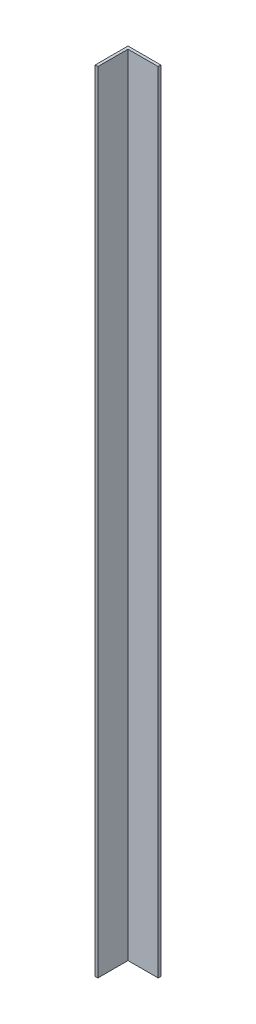
from build123d import *

# Parameters (mm, degrees)
EXTRUDE_THIN1_DEPTH = 457.2


with BuildPart() as part:
    # Sketch1 → Extrude-Thin1 (new body)
    with BuildSketch(Plane(origin=(0, 0, 0), x_dir=(1, 0, 0), z_dir=(0, 1, 0))):
        Polygon((0, 0), (0, 19.05), (19.05, 19.05), (19.05, 17.4625), (1.5875, 17.4625), (1.5875, 0), align=None)
    extrude(amount=EXTRUDE_THIN1_DEPTH)


solid = part.part
